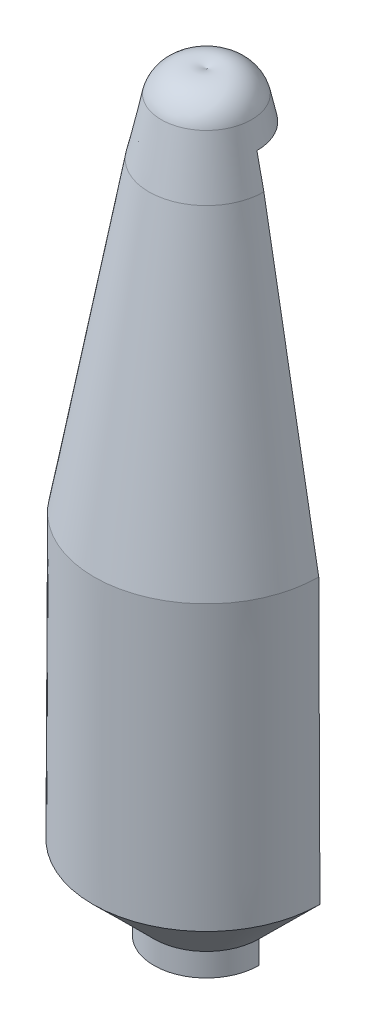
from build123d import *

# Parameters (mm, degrees)
SKETCH4_W      = 4011.07088781
SKETCH4_H      = 13014.337916561
EXTRUDE1_DEPTH = 2540


with BuildPart() as part:
    # Sketch1 → Revolve1 (revolve)
    with BuildSketch(Plane(origin=(0, 0, 0), x_dir=(0, 0, -1), z_dir=(1, 0, 0))):
        with BuildLine():
            Line((889, 5386.324), (1854.2, 0.000254))
            Line((1854.2, 0.000254), (1854.2, -914.399746))
            Line((1854.2, -914.399746), (1875.028, -914.399746))
            Line((1875.028, -914.399746), (1875.028, -4925.059746))
            Line((1875.028, -4925.059746), (797.687, -5991.859746))
            Line((797.687, -5991.859746), (797.687, -6450.585559605))
            Line((797.687, -6450.585559605), (924.687, -6450.585559605))
            Line((924.687, -6450.585559605), (924.687, -6044.830978169))
            Line((924.687, -6044.830978169), (2002.028, -4978.030978169))
            Line((2002.028, -4978.030978169), (1981.2, 11.289201635))
            Line((1981.2, 11.289201635), (1014.008798645, 5408.724898673))
            Line((1014.008798645, 5408.724898673), (797.687, 6403.505182835))
            ThreePointArc((797.687, 6403.505182835), (486.180167613, 6776.837110866), (0, 6783.324))
            Line((0, 6783.324), (0, 5386.324))
            Line((0, 5386.324), (889, 5386.324))
        make_face()
    revolve(axis=Axis((0, 0, 0), (0, 1, 0)))

    # Sketch4 → Extrude1 (cut, symmetric)
    with BuildSketch(Plane(origin=(0, 0, 0), x_dir=(0, 0, -1), z_dir=(1, 0, 0))):
        with Locations((2005.535443905, -530.033294357)):
            Rectangle(SKETCH4_W, SKETCH4_H)
    extrude(amount=EXTRUDE1_DEPTH, both=True, mode=Mode.SUBTRACT)


solid = part.part
